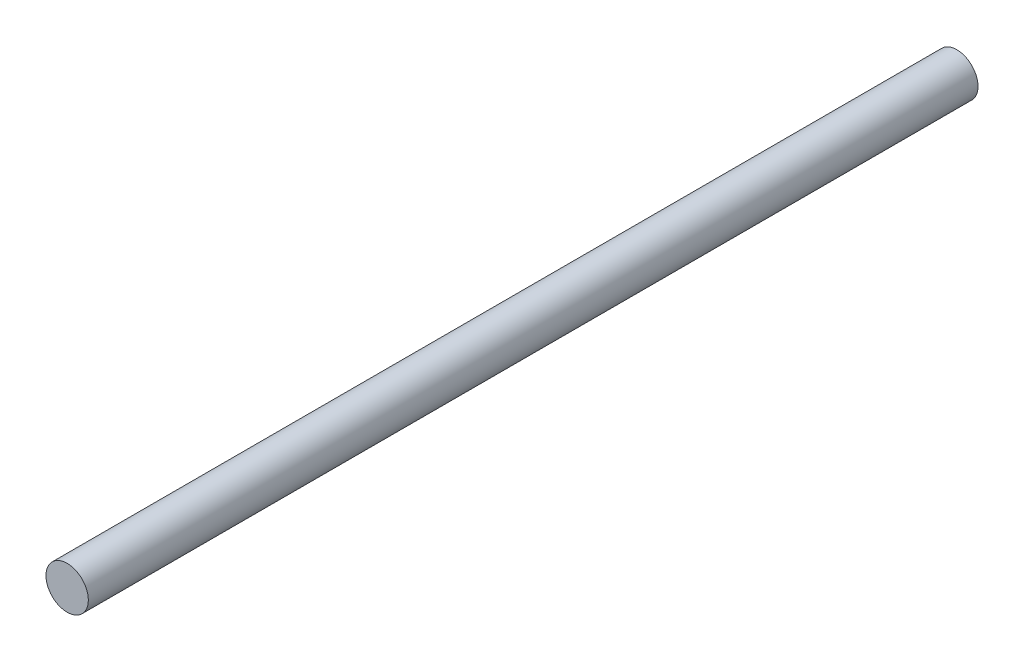
from build123d import *

# Parameters (mm, degrees)
SKETCH_1_R      = 2
EXTRUDE_1_DEPTH = 84


with BuildPart() as part:
    # 草图1 → 凸台-拉伸1 (new body)
    with BuildSketch(Plane.XY):
        Circle(SKETCH_1_R)
    extrude(amount=EXTRUDE_1_DEPTH)


solid = part.part
